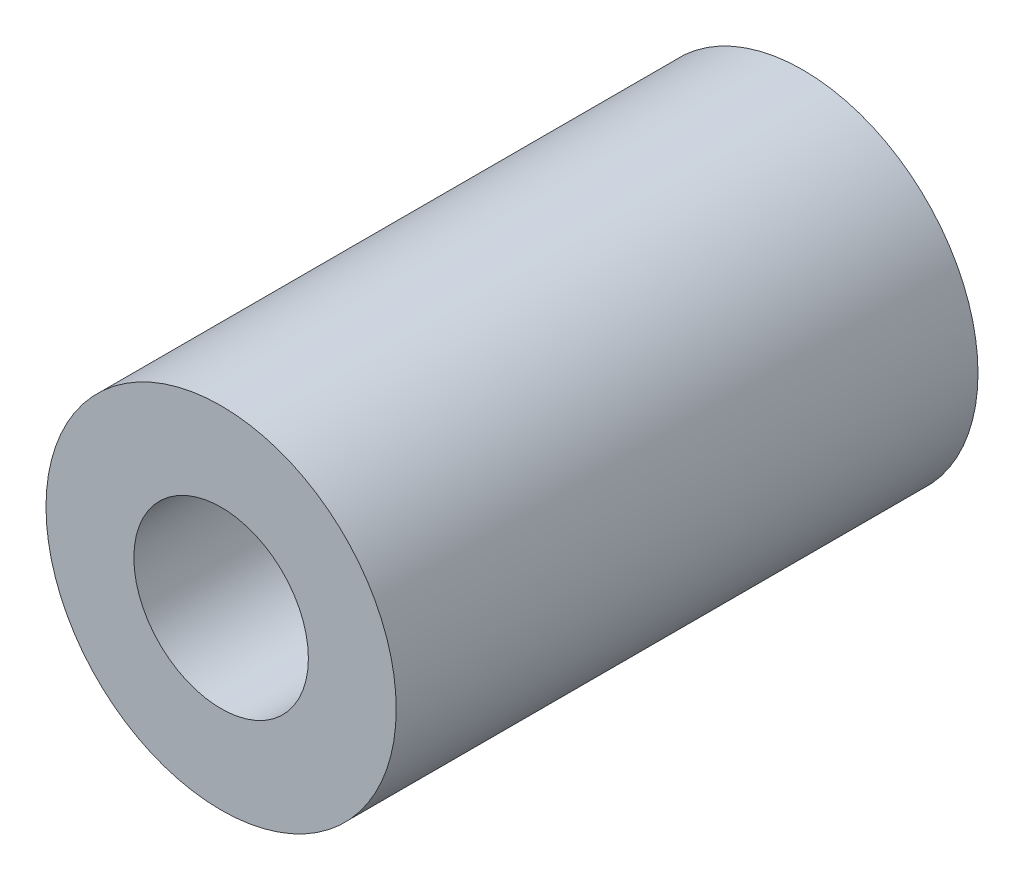
from build123d import *

# Parameters (mm, degrees)
SKETCH1_R      = 3.01
SKETCH1_R_2    = 1.5
EXTRUDE1_DEPTH = 5


with BuildPart() as part:
    # Sketch1 → Extrude1 (new body, symmetric)
    with BuildSketch(Plane.XY):
        Circle(SKETCH1_R)
        Circle(SKETCH1_R_2, mode=Mode.SUBTRACT)
    extrude(amount=EXTRUDE1_DEPTH, both=True)


solid = part.part
